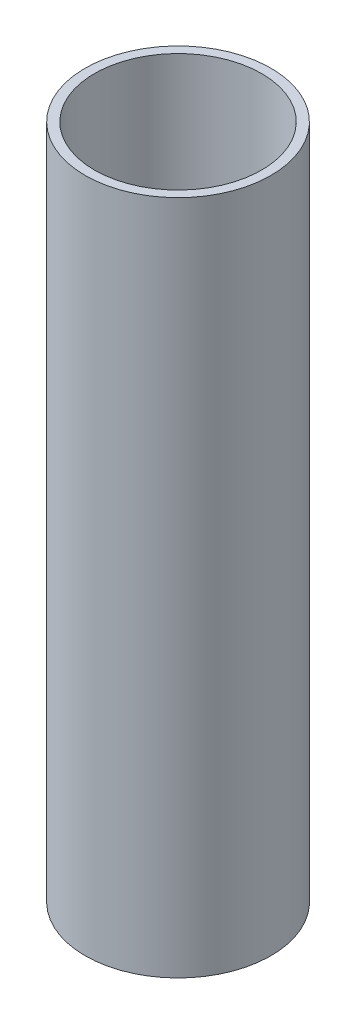
from build123d import *

# Parameters (mm, degrees)
SKETCH1_R           = 16.5
SKETCH1_R_2         = 14.85
BOSS_EXTRUDE1_DEPTH = 60


with BuildPart() as part:
    # Sketch1 → Boss-Extrude1 (new body, symmetric)
    with BuildSketch(Plane(origin=(0, 0, 0), x_dir=(1, 0, 0), z_dir=(0, 1, 0))):
        Circle(SKETCH1_R)
        Circle(SKETCH1_R_2, mode=Mode.SUBTRACT)
    extrude(amount=BOSS_EXTRUDE1_DEPTH, both=True)


solid = part.part
